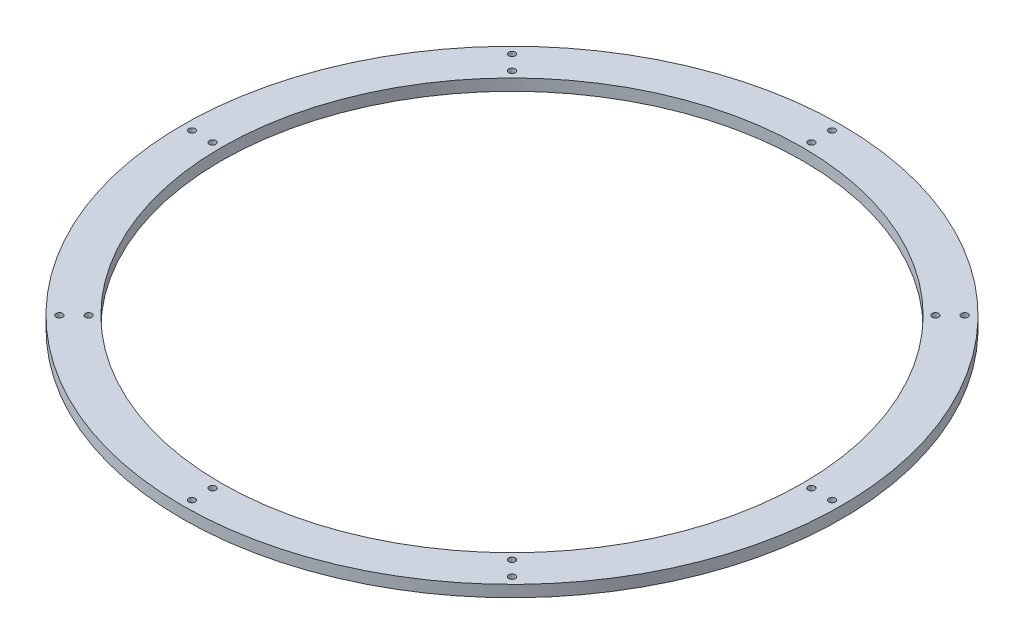
from build123d import *

# Parameters (mm, degrees)
SKETCH1_R           = 399
BOSS_EXTRUDE1_DEPTH = 14
SKETCH2_R           = 352
CUT_EXTRUDE1_DEPTH  = 14
SKETCH4_R           = 4
CUT_EXTRUDE2_DEPTH  = 19.304
CIRPATTERN1_COUNT   = 8
SKETCH7_R           = 4
CUT_EXTRUDE3_DEPTH  = 15
CIRPATTERN2_COUNT   = 8


with BuildPart() as part:
    # Sketch1 → Boss-Extrude1 (new body)
    with BuildSketch(Plane(origin=(0, 0, 0), x_dir=(1, 0, 0), z_dir=(0, 1, 0))):
        Circle(SKETCH1_R)
    extrude(amount=BOSS_EXTRUDE1_DEPTH)

    # Sketch2 → Cut-Extrude1 (cut)
    with BuildSketch(Plane(origin=(0, 14, 0), x_dir=(1, 0, 0), z_dir=(0, 1, 0))):
        Circle(SKETCH2_R)
    extrude(amount=-CUT_EXTRUDE1_DEPTH, mode=Mode.SUBTRACT)

    # Sketch4 → Cut-Extrude2 (cut)
    with BuildSketch(Plane(origin=(0, 0, 0), x_dir=(-1, 0, 0), z_dir=(0, -1, 0))):
        with Locations((0, 387.5)):
            Circle(SKETCH4_R)
    cut_extrude2 = extrude(amount=-CUT_EXTRUDE2_DEPTH, mode=Mode.SUBTRACT)

    # CirPattern1: Cut-Extrude2 ×8 about axis
    cirpattern1_axis = Axis((0, 0, 0), (0, 1, 0))
    for i in range(1, CIRPATTERN1_COUNT):
        add(cut_extrude2.rotate(cirpattern1_axis, i * 360 / CIRPATTERN1_COUNT), mode=Mode.SUBTRACT)

    # Sketch7 → Cut-Extrude3 (cut, through all)
    with BuildSketch(Plane(origin=(0, 14, 0), x_dir=(1, 0, 0), z_dir=(0, 1, 0))):
        with Locations((0, 362.5)):
            Circle(SKETCH7_R)
    cut_extrude3 = extrude(amount=-CUT_EXTRUDE3_DEPTH, mode=Mode.SUBTRACT)

    # CirPattern2: Cut-Extrude3 ×8 about axis
    cirpattern2_axis = Axis((0, 0, 0), (0, 1, 0))
    for i in range(1, CIRPATTERN2_COUNT):
        add(cut_extrude3.rotate(cirpattern2_axis, i * 360 / CIRPATTERN2_COUNT), mode=Mode.SUBTRACT)


solid = part.part
